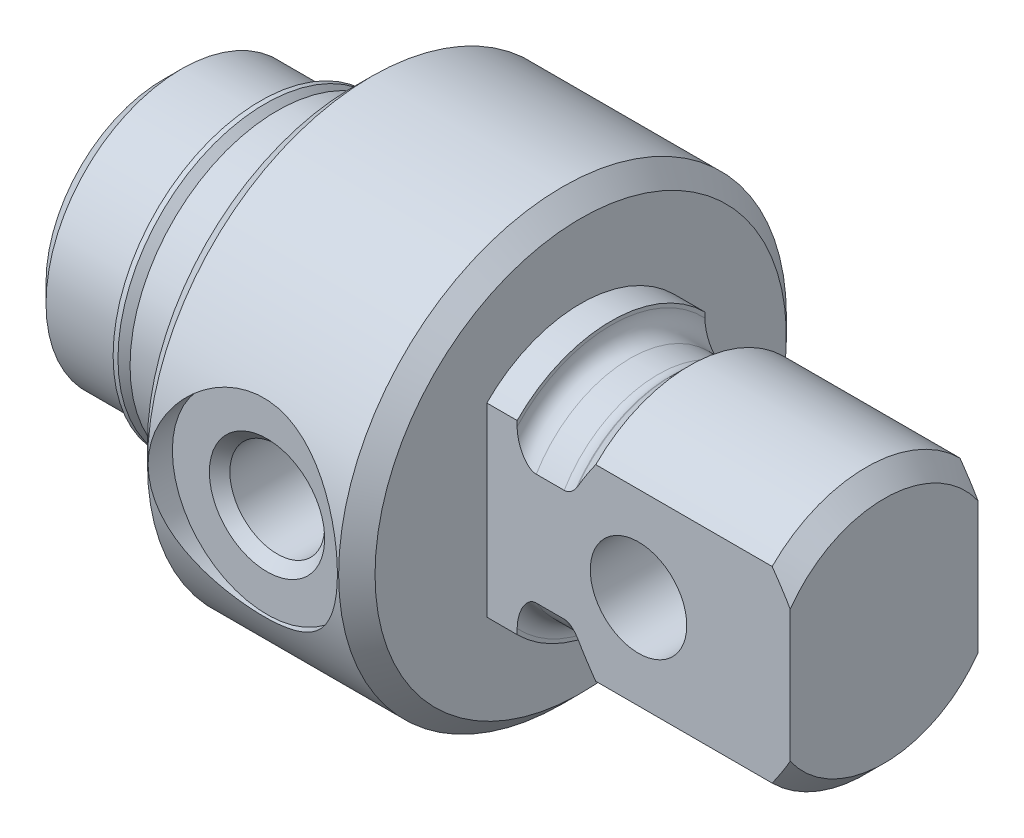
from build123d import *

# Parameters (mm, degrees)
SKETCH3_W               = 37.4904
SKETCH3_H               = 74.9808
SKETCH3_W_2             = 7.8613
SKETCH3_H_2             = 37.4904
CUT_EXTRUDE1_DEPTH      = 12.7
HOLE1_D                 = 4.7625
HOLE1_DEPTH             = 17.4625
HOLE1_TIP               = 1.374815329
CUT_EXTRUDE2_DEPTH      = 5.895975
CUT_EXTRUDE2_DEPTH_BACK = 5.895975
SKETCH8_R               = 2.0193


with BuildPart() as part:
    # Sketch1 → Revolve1 (revolve)
    with BuildSketch(Plane.XY):
        Polygon((0, 0), (0, 4.90855), (0.762, 5.67055), (3.7592, 5.67055), (4.2672, 5.16255), (4.7752, 5.16255), (4.7752, 6.16585), (7.9502, 6.16585), (7.9502, 8.6106), (8.7122, 9.3726), (16.7132, 9.3726), (17.4752, 8.6106), (17.4752, 0), align=None)
    revolve(axis=Axis((17.4752, 0, 0), (-1, 0, 0)))

    # Sketch2 → Revolve2 (revolve)
    with BuildSketch(Plane.XY):
        with BuildLine():
            Line((17.4752, 0), (17.4752, 5.5245))
            Line((17.4752, 5.5245), (18.7452, 5.5245))
            Line((18.7452, 5.5245), (18.7452, 5.3721))
            ThreePointArc((18.7452, 5.3721), (18.979543864, 4.806343864), (19.5453, 4.572))
            Line((19.5453, 4.572), (20.7137, 4.572))
            ThreePointArc((20.7137, 4.572), (20.9804, 4.617758486), (21.216594343, 4.7498))
            Line((21.216594343, 4.7498), (21.279456136, 4.8006))
            Line((21.279456136, 4.8006), (22.035106136, 5.55625))
            Line((22.035106136, 5.55625), (29.41955, 5.55625))
            Line((29.41955, 5.55625), (30.1752, 4.8006))
            Line((30.1752, 4.8006), (30.1752, 0))
            Line((30.1752, 0), (17.4752, 0))
        make_face()
    revolve(axis=Axis((30.1752, 0, 0), (-1, 0, 0)))

    # Sketch3 → Cut-Extrude1 (cut)
    with BuildSketch(Plane(origin=(30.1752, 0, 0), x_dir=(0, 0, -1), z_dir=(1, 0, 0))):
        Rectangle(SKETCH3_W, SKETCH3_H)
        Rectangle(SKETCH3_W_2, SKETCH3_H_2, mode=Mode.SUBTRACT)
    extrude(amount=-CUT_EXTRUDE1_DEPTH, mode=Mode.SUBTRACT)

    # Hole1
    with Locations(Plane.ZY):
        with Locations((0, 0)):
            Hole(HOLE1_D / 2, depth=HOLE1_DEPTH)
            with Locations((0, 0, -(HOLE1_DEPTH + HOLE1_TIP / 2))):  # 120° drill point
                Cone(0, HOLE1_D / 2, HOLE1_TIP, mode=Mode.SUBTRACT)

    # Sketch6 → Cut-Revolve1 (revolve, cut)
    with BuildSketch(Plane(origin=(0, 0, 0), x_dir=(1, 0, 0), z_dir=(0, 1, 0))):
        Polygon((12.7, 0), (14.68374, 0), (14.68374, -7.92734), (15.113, -8.3566), (16.6624, -8.3566), (16.6624, -9.3726), (12.7, -9.3726), align=None)
    revolve(axis=Axis((12.7, 0, 9.3726), (0, 0, -1)), mode=Mode.SUBTRACT)

    # Sketch7 → Revolve3 (revolve)
    with BuildSketch(Plane.XY):
        with BuildLine():
            Line((4.066488686, 6.081681804), (4.663607684, 5.484562806))
            ThreePointArc((4.663607684, 5.484562806), (4.700805122, 5.394760245), (4.663607684, 5.304957684))
            Line((4.663607684, 5.304957684), (4.5212, 5.16255))
            Line((4.5212, 5.16255), (4.2672, 5.16255))
            Line((4.2672, 5.16255), (4.2672, 4.90855))
            Line((4.2672, 4.90855), (4.7752, 4.90855))
            Line((4.7752, 4.90855), (4.7752, 5.660338686))
            Line((4.7752, 5.660338686), (4.269688686, 6.16585))
            Line((4.269688686, 6.16585), (4.066488686, 6.16585))
            Line((4.066488686, 6.16585), (4.066488686, 6.081681804))
        make_face()
    revolve(axis=Axis((4.7752, 0, 0), (-1, 0, 0)))

    # Sketch8 → Cut-Extrude2 (cut, two sides: drawn at the far end of the back side and taken through both)
    with BuildSketch(Plane.XY.offset(-CUT_EXTRUDE2_DEPTH_BACK)):
        with Locations((23.8252, 0)):
            Circle(SKETCH8_R)
    extrude(amount=CUT_EXTRUDE2_DEPTH + CUT_EXTRUDE2_DEPTH_BACK, mode=Mode.SUBTRACT)


solid = part.part
